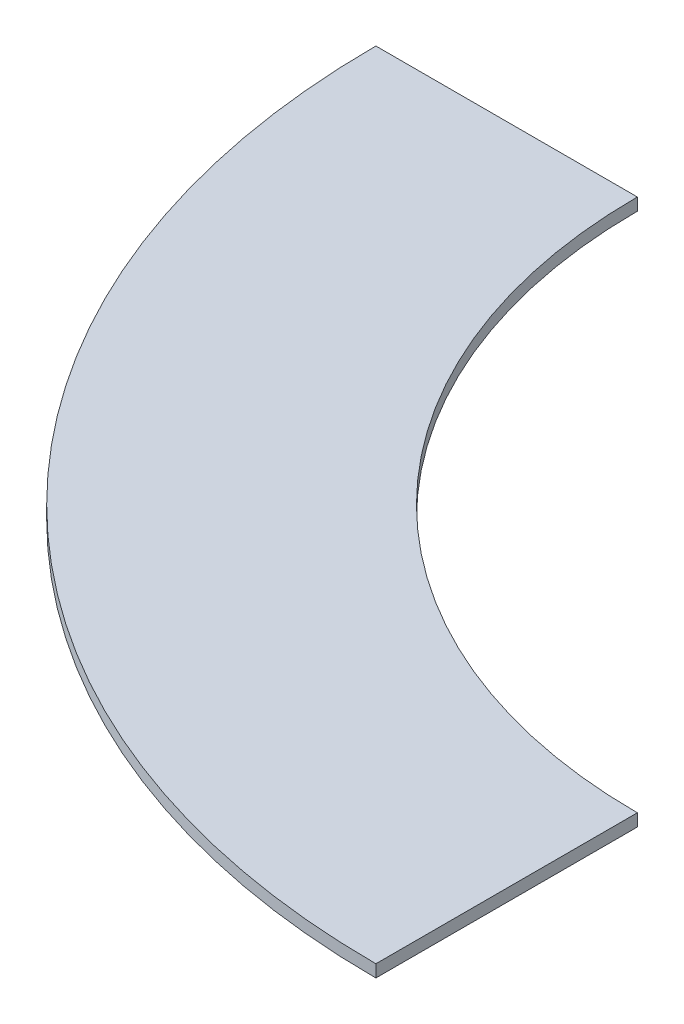
from build123d import *

# Parameters (mm, degrees)
BOSS_EXTRUDE1_DEPTH = 7.9375


with BuildPart() as part:
    # Sketch1 → Boss-Extrude1 (new body)
    with BuildSketch(Plane(origin=(0, 0, 0), x_dir=(1, 0, 0), z_dir=(0, 1, 0))):
        with BuildLine():
            ThreePointArc((0, -342.9635), (-242.511816549, -242.511816549), (-342.9635, 0))
            Line((-342.9635, 0), (-511.1115, 0))
            ThreePointArc((-511.1115, 0), (-361.410407592, -361.410407592), (0, -511.1115))
            Line((0, -511.1115), (0, -342.9635))
        make_face()
    extrude(amount=BOSS_EXTRUDE1_DEPTH)


solid = part.part
